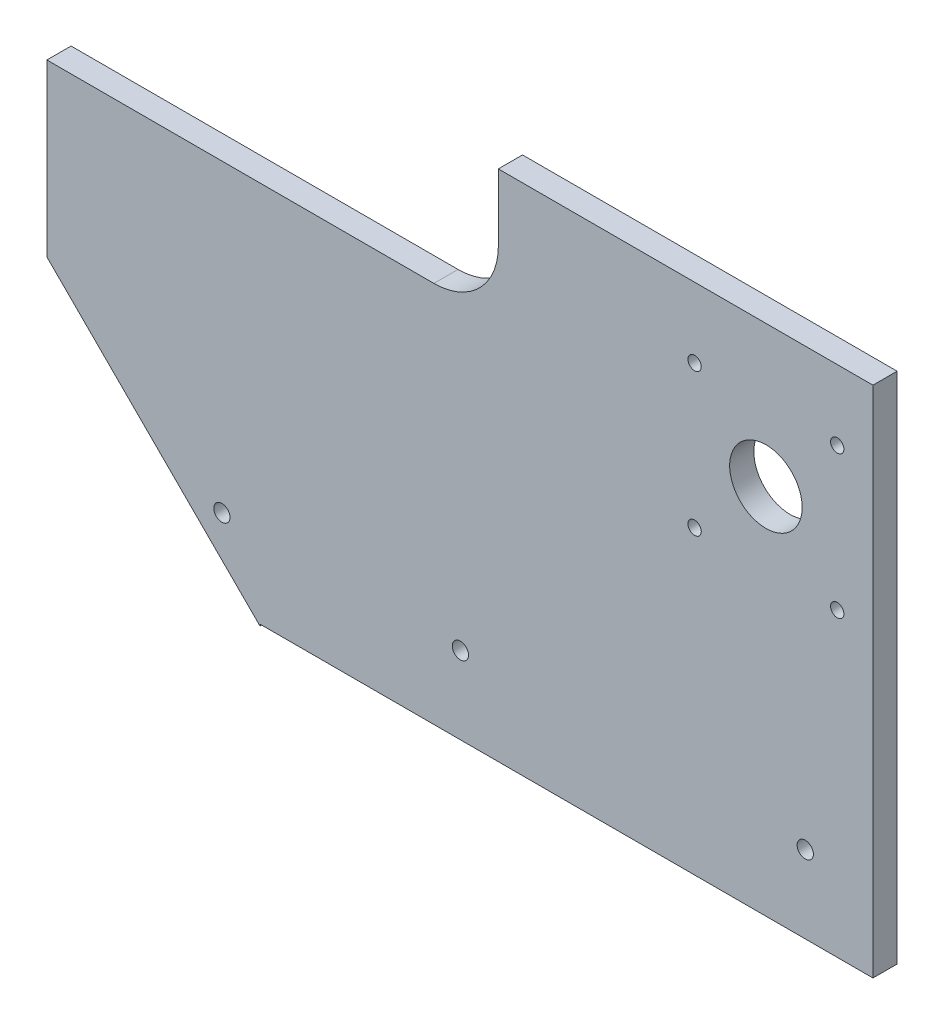
from build123d import *

# Parameters (mm, degrees)
SKETCH1_R                    = 14.2875
BOSS_EXTRUDE1_DEPTH          = 9.525
SKETCH2_W                    = 260.572878056
SKETCH2_H                    = 51.689000001
CUT_EXTRUDE1_DEPTH           = 10.525
SKETCH4_W                    = 213.36
SKETCH4_H                    = 68.767352002
CUT_EXTRUDE2_DEPTH           = 10.525
FILLET2_R                    = 25.4
SKETCH16_W                   = 9.525
SKETCH16_H                   = 4.28736328
CUT_EXTRUDE3_DEPTH           = 361.970011278
SKETCH17_W                   = 147.610011278
SKETCH17_H                   = 12.7
CUT_EXTRUDE4_DEPTH           = 10.525
TAP_DRILL_FOR_M6X0_75_TAP1_D = 5.25
F_6_4_6_4_DIAMETER_HOLE1_D   = 6.4
CUT_EXTRUDE5_DEPTH           = 10.525


with BuildPart() as part:
    # Sketch1 → Boss-Extrude1 (new body)
    with BuildSketch(Plane.XY):
        Polygon((-138.259383474, 48.991487021), (32.210627804, -121.478524257), (222.710627804, -121.478524257), (222.710627804, 149.508839023), (-138.259383474, 149.508839023), align=None)
        with Locations((180.538014078, 76.831975743)):
            Circle(SKETCH1_R, mode=Mode.SUBTRACT)
    extrude(amount=BOSS_EXTRUDE1_DEPTH)

    # Sketch2 → Cut-Extrude1 (cut, through all)
    with BuildSketch(Plane.XY.offset(9.525)):
        with Locations((111.474188776, -95.634024256)):
            Rectangle(SKETCH2_W, SKETCH2_H)
    extrude(amount=-CUT_EXTRUDE1_DEPTH, mode=Mode.SUBTRACT)

    # Sketch4 → Cut-Extrude2 (cut, through all)
    with BuildSketch(Plane.XY.offset(9.525)):
        with Locations((-31.579383474, 115.125163022)):
            Rectangle(SKETCH4_W, SKETCH4_H)
    extrude(amount=-CUT_EXTRUDE2_DEPTH, mode=Mode.SUBTRACT)

    # Fillet2
    fillet2_edges = [part.edges().sort_by_distance(p)[0] for p in [
        (-138.259383474, 80.741487021, 4.7625),
        (75.100616526, 80.741487021, 4.7625),
    ]]
    fillet(fillet2_edges, radius=FILLET2_R)

    # Sketch16 → Cut-Extrude3 (cut, through all)
    with BuildSketch(Plane(origin=(222.710627804, 0, 0), x_dir=(0, 0, -1), z_dir=(1, 0, 0))):
        with Locations((-4.7625, 147.365157383)):
            Rectangle(SKETCH16_W, SKETCH16_H)
    extrude(amount=-CUT_EXTRUDE3_DEPTH, mode=Mode.SUBTRACT)

    # Sketch17 → Cut-Extrude4 (cut, through all)
    with BuildSketch(Plane(origin=(0, 0, 0), x_dir=(-1, 0, 0), z_dir=(0, 0, -1))):
        with Locations((-148.905622165, 138.871475743)):
            Rectangle(SKETCH17_W, SKETCH17_H)
    extrude(amount=-CUT_EXTRUDE4_DEPTH, mode=Mode.SUBTRACT)

    # Tap Drill for M6x0.75 Tap1 (through all)
    with Locations(Plane.XY.offset(9.525)):
        with Locations((208.638014078, 104.931975743), (152.438014078, 104.931975743), (152.438014078, 48.731975743), (208.638014078, 48.731975743)):
            Hole(TAP_DRILL_FOR_M6X0_75_TAP1_D / 2)

    # Ø6.4 (6.4) Diameter Hole1 (through all)
    with Locations(Plane.XY.offset(9.525)):
        with Locations((196.040627804, -39.314524257), (60.150627804, -39.314524257), (-33.829372196, -39.314524257)):
            Hole(F_6_4_6_4_DIAMETER_HOLE1_D / 2)

    # Sketch22 → Cut-Extrude5 (cut, through all)
    with BuildSketch(Plane.XY.offset(9.525)):
        Polygon((-102.790372196, 145.085482826), (-102.790372196, -100.339530139), (-209.67575658, -95.573995907), (-209.67575658, 145.085482826), align=None)
    extrude(amount=-CUT_EXTRUDE5_DEPTH, mode=Mode.SUBTRACT)


solid = part.part
